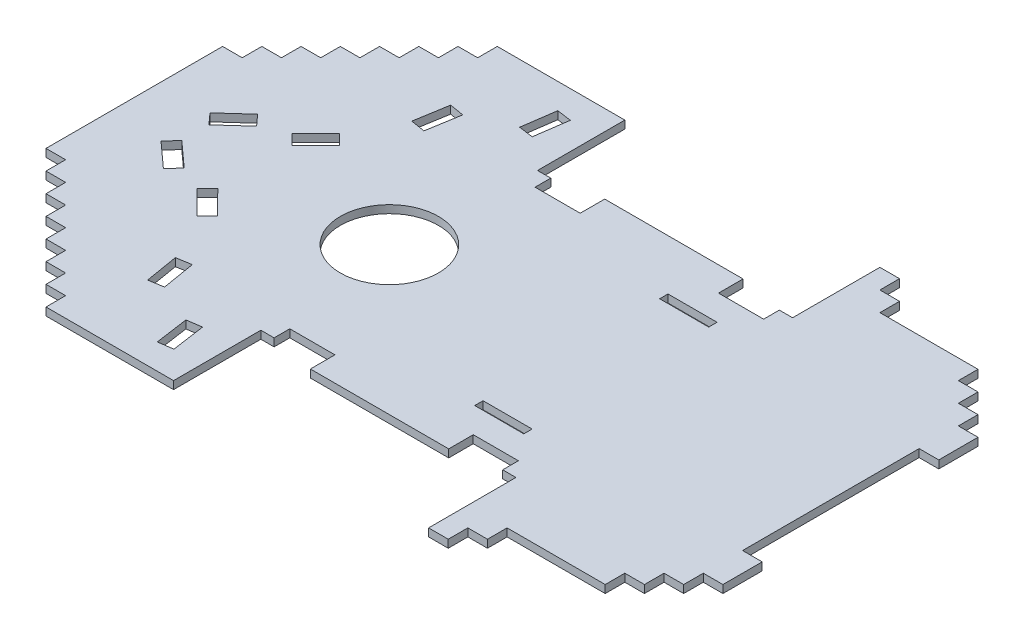
from build123d import *

# Parameters (mm, degrees)
SKETCH_5_R      = 5
SKETCH_5_W      = 5
SKETCH_5_H      = 0.85
EXTRUDE_1_DEPTH = 0.8


with BuildPart() as part:
    # 스케치5 → 보스-돌출1 (new body)
    with BuildSketch(Plane(origin=(0, 0, 0), x_dir=(1, 0, 0), z_dir=(0, 1, 0))):
        Polygon((-13, -23), (-13, -14.1), (-11.65, -14.1), (-11.65, -12.5), (-7.05, -12.5), (-7.05, -14.1), (-7.05, -15), (7.05, -15), (7.05, -14.1), (7.05, -12.5), (11.65, -12.5), (11.65, -14.1), (13, -14.1), (13, -23), (15, -23), (15, -21), (17, -21), (17, -19), (27, -19), (27, -17), (29, -17), (29, -15), (31, -15), (31, -13), (33, -13), (33, -9), (31, -9), (31, 9), (33, 9), (33, 13), (31, 13), (31, 15), (29, 15), (29, 17), (27, 17), (27, 19), (17, 19), (17, 21), (15, 21), (15, 23), (13, 23), (13, 14.1), (11.65, 14.1), (11.65, 12.5), (7.05, 12.5), (7.05, 14.1), (7.05, 15), (-7.05, 15), (-7.05, 14.1), (-7.05, 12.5), (-11.65, 12.5), (-11.65, 14.1), (-13, 14.1), (-13, 23), (-26, 23), (-26, 21), (-28, 21), (-28, 19), (-30, 19), (-30, 17), (-32, 17), (-32, 15), (-34, 15), (-34, 13), (-36, 13), (-36, 11), (-38, 11), (-38, 9), (-40, 9), (-40, -9), (-38, -9), (-38, -11), (-36, -11), (-36, -13), (-34, -13), (-34, -15), (-32, -15), (-32, -17), (-30, -17), (-30, -19), (-28, -19), (-28, -21), (-26, -21), (-26, -23), align=None)
        with Locations((-14, 0)):
            Circle(SKETCH_5_R, mode=Mode.SUBTRACT)
        Polygon((-17.728524487, -17.009831185), (-17.241222705, -20.415141299), (-15.756349109, -20.202655057), (-16.243650891, -16.797344943), align=None, mode=Mode.SUBTRACT)
        Polygon((-23.763263852, -12.051103665), (-23.19560882, -15.443944328), (-21.716172484, -15.196420332), (-22.283827516, -11.803579668), align=None, mode=Mode.SUBTRACT)
        Polygon((-28.776184385, -4.834516937), (-26.354359033, -7.277540056), (-25.289087324, -6.22151156), (-27.710912676, -3.77848844), align=None, mode=Mode.SUBTRACT)
        Polygon((-32.230719309, -4.802671603), (-34.781815362, -2.494965181), (-33.775548026, -1.382568646), (-31.224451974, -3.690275068), align=None, mode=Mode.SUBTRACT)
        Polygon((-17.241222705, 20.415141299), (-15.756349109, 20.202655057), (-16.243650891, 16.797344943), (-17.728524487, 17.009831185), align=None, mode=Mode.SUBTRACT)
        Polygon((-23.19560882, 15.443944328), (-21.716172484, 15.196420332), (-22.283827516, 11.803579668), (-23.763263852, 12.051103665), align=None, mode=Mode.SUBTRACT)
        Polygon((-26.354359033, 7.277540056), (-25.289087324, 6.22151156), (-27.710912676, 3.77848844), (-28.776184385, 4.834516937), align=None, mode=Mode.SUBTRACT)
        Polygon((-34.781815362, 2.494965181), (-33.775548026, 1.382568646), (-31.224451974, 3.690275068), (-32.230719309, 4.802671603), align=None, mode=Mode.SUBTRACT)
        with Locations((7.05, 9.425)):
            Rectangle(SKETCH_5_W, SKETCH_5_H, mode=Mode.SUBTRACT)
        with Locations((7.05, -9.425)):
            Rectangle(SKETCH_5_W, SKETCH_5_H, mode=Mode.SUBTRACT)
    extrude(amount=EXTRUDE_1_DEPTH)


solid = part.part
